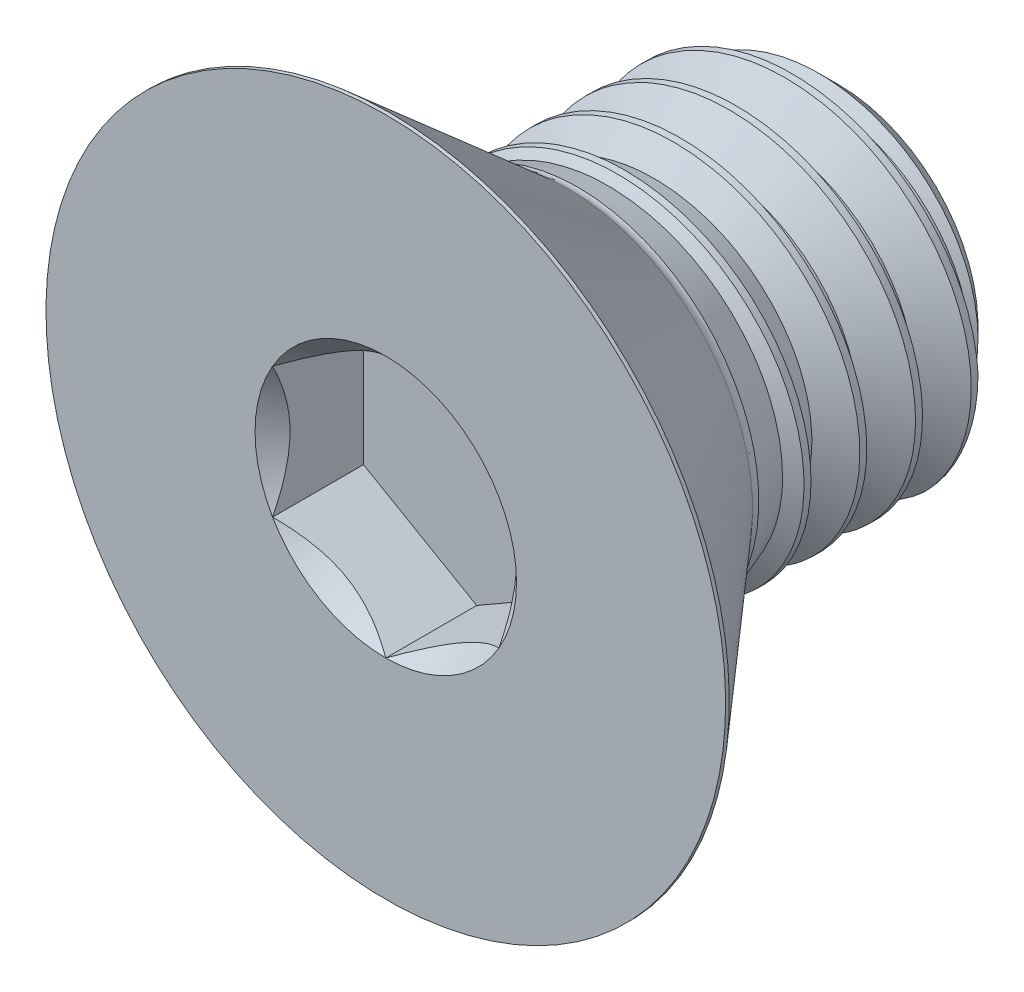
from build123d import *

# Parameters (mm, degrees)
SKETCH10_R          = 4.582717761692655
CUT_EXTRUDE2_DEPTH  = 3.1877
CUT_EXTRUDE2_DRAFT  = -45.0000000000001
CUT_EXTRUDE1_DEPTH  = 3.1877
CUT_SWEEP1_PITCH    = 1.9538461538461593
CUT_SWEEP1_HEIGHT   = 15.875000000000021
CUT_SWEEP1_RADIUS   = 6.350000000000006
SKETCH7_R           = 6.35
BOSS_EXTRUDE2_DEPTH = 9.148181
BOSS_EXTRUDE2_DRAFT = -20.000000000000043


with BuildPart() as part:
    # Sketch2 → Revolve1 (revolve)
    with BuildSketch(Plane(origin=(0, 0, 0), x_dir=(0, 0, -1), z_dir=(1, 0, 0))):
        with BuildLine():
            Line((-7.809992, 11.9126), (-1.5621000000000003, 6.481390345091882))
            ThreePointArc((-1.5621000000000003, 6.481390345091882), (-1.398269901870612, 6.3839216791105144), (-1.2106805589227891, 6.35))
            Line((-1.2106805589227891, 6.35), (6.472115384615384, 6.350000000000003))
            Line((6.472115384615384, 6.350000000000003), (7.9375, 4.884615384615372))
            Line((7.9375, 4.884615384615372), (7.9375, -2.26e-15))
            Line((7.9375, -2.26e-15), (-7.9375, -2.27e-15))
            Line((-7.9375, -2.27e-15), (-7.9375, 11.9126))
            Line((-7.9375, 11.9126), (-7.809992, 11.9126))
        make_face()
    revolve(axis=Axis((0, -2.26e-15, -7.9375), (0, 0, 1)))


with BuildPart() as cut_extrude2_tool:
    # Sketch10 → Cut-Extrude2 (with draft: the straight prism first)
    with BuildSketch(Plane.XY.offset(7.9375)):
        Circle(SKETCH10_R)
    extrude(amount=-CUT_EXTRUDE2_DEPTH)
    # Cut-Extrude2: the draft: its side faces are tilted about the plane it starts from
    cut_extrude2_sides = [cut_extrude2_tool.faces().sort_by_distance(p)[0] for p in [
        (-4.582717762, 0, 6.34365),
    ]]
    draft(cut_extrude2_sides, Plane.XY.offset(7.9375), CUT_EXTRUDE2_DRAFT)


with BuildPart() as part_1:
    add(part.part)

    # Cut-Extrude2: cut by cut_extrude2_tool
    add(cut_extrude2_tool.part, mode=Mode.SUBTRACT)

    # Sketch9 → Cut-Extrude1 (cut)
    with BuildSketch(Plane.XY.offset(7.9375)):
        Polygon((3.96875, -2.291358880846329), (3.96875, 2.2913588808463294), (1.33e-15, 4.582717761692655), (-3.96875, 2.291358880846329), (-3.96875, -2.2913588808463268), (-1.6e-16, -4.582717761692654), align=None)
    extrude(amount=-CUT_EXTRUDE1_DEPTH, mode=Mode.SUBTRACT)


with BuildPart() as body_2:
    # Split1: the piece on the far side of the plane
    add(part_1.part)
    split(bisect_by=Plane.XY.offset(1.2106805589227891), keep=Keep.BOTTOM)

    # Cut-Sweep1: sweep along a helix
    with BuildLine() as cut_sweep1_path:
        Helix(CUT_SWEEP1_PITCH, CUT_SWEEP1_HEIGHT, CUT_SWEEP1_RADIUS, center=(0, -1.63e-15, -7.9375), direction=(0, -1.8e-16, 1))
    # Sketch4 → Cut-Sweep1 (sweep, cut)
    with BuildSketch(Plane(origin=(0, 0, 0), x_dir=(0, 0, -1), z_dir=(1, 0, 0))):
        Polygon((7.876442307692306, 6.455755025269834), (9.708173076923078, 6.455755025269834), (8.914423076923077, 5.080939696762041), (8.670192307692306, 5.080939696762041), align=None)
    sweep(path=cut_sweep1_path.line, is_frenet=True, mode=Mode.SUBTRACT)


with BuildPart() as part_2:
    add(part_1.part)

    # Split1
    split(bisect_by=Plane.XY.offset(1.2106805589227891), keep=Keep.TOP)


with BuildPart() as boss_extrude2_tool:
    # Sketch7 → Boss-Extrude2 (with draft: the straight prism first)
    with BuildSketch(Plane.XY.offset(1.2106805589227891)):
        Circle(SKETCH7_R)
    extrude(amount=-BOSS_EXTRUDE2_DEPTH)
    # Boss-Extrude2: the draft: its side faces are tilted about the plane it starts from
    boss_extrude2_sides = [boss_extrude2_tool.faces().sort_by_distance(p)[0] for p in [
        (-6.35, 0, -3.363409941),
    ]]
    draft(boss_extrude2_sides, Plane.XY.offset(1.2106805589227891), BOSS_EXTRUDE2_DRAFT)


with BuildPart() as part_3:
    add(part_2.part)

    # Boss-Extrude2: add boss_extrude2_tool
    add(boss_extrude2_tool.part)

    add(body_2.part)  # Boss-Extrude2 merges body 2


solid = part_3.part
